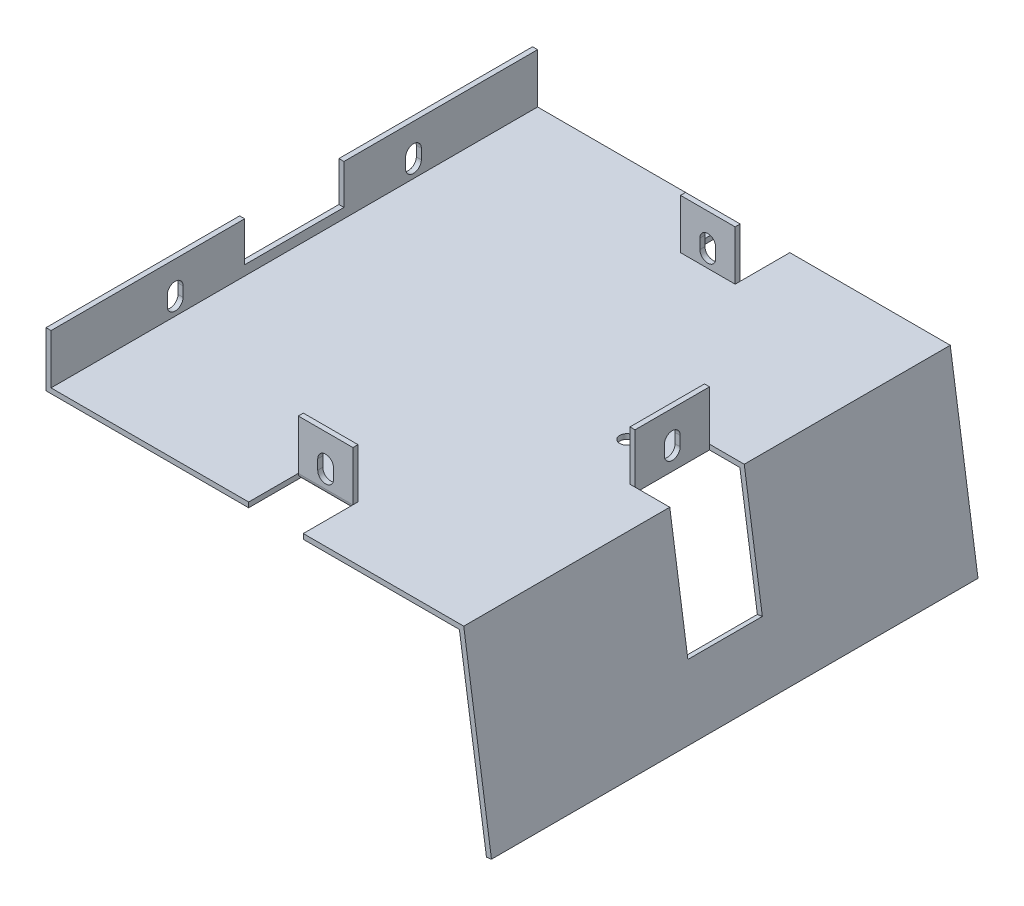
from build123d import *

# Parameters (mm, degrees)
BOSS_EXTRUDE1_DEPTH = 98
CUT_EXTRUDE1_REACH  = 40.016
SKETCH2_W           = 11
SKETCH2_H           = 10
SKETCH4_W           = 11
SKETCH4_H           = 10
BOSS_EXTRUDE2_DEPTH = 1.016
FILLET2_R           = 1
CUT_EXTRUDE2_REACH  = 40.016
SKETCH6_R           = 1.4224
FILLET4_R           = 1
CUT_EXTRUDE4_REACH  = 91.728
SKETCH8_W           = 20
SKETCH8_H           = 8.016
CUT_EXTRUDE5_REACH  = 90.79
SKETCH9_W           = 15
SKETCH9_H           = 22
CUT_EXTRUDE6_REACH  = 40.016
SKETCH11_W          = 15
SKETCH11_H          = 10
BOSS_EXTRUDE4_DEPTH = 1.016
CUT_EXTRUDE7_REACH  = 79.143


with BuildPart() as part:
    # Sketch1 → Boss-Extrude1 (new body)
    with BuildSketch(Plane.XY):
        Polygon((0, 0), (-5.457086284, 37), (-87.707086284, 37), (-88.723086284, 37), (-88.723086284, 48.016), (-87.707086284, 48.016), (-87.707086284, 38.016), (-4.579943874, 38.016), (1.005126579, 0.148244932), align=None)
    extrude(amount=BOSS_EXTRUDE1_DEPTH)

    # Sketch2 → Cut-Extrude1 (cut, up to next)
    with BuildSketch(Plane(origin=(0, 38.016, 0), x_dir=(1, 0, 0), z_dir=(0, 1, 0)), mode=Mode.PRIVATE) as cut_extrude1_sk1:
        with Locations((-42.399943874, -5)):
            Rectangle(SKETCH2_W, SKETCH2_H)
    cut_extrude1_tool1 = extrude(cut_extrude1_sk1.sketch, amount=-CUT_EXTRUDE1_REACH, mode=Mode.PRIVATE) & part.part
    add(cut_extrude1_tool1.solids().sort_by_distance((-42.399944, 38.016, 5))[0], mode=Mode.SUBTRACT)
    # Sketch2 → Cut-Extrude1 (cut, up to next)
    with BuildSketch(Plane(origin=(0, 38.016, 0), x_dir=(1, 0, 0), z_dir=(0, 1, 0)), mode=Mode.PRIVATE) as cut_extrude1_sk2:
        with Locations((-42.399943874, -93)):
            Rectangle(SKETCH2_W, SKETCH2_H)
    cut_extrude1_tool2 = extrude(cut_extrude1_sk2.sketch, amount=-CUT_EXTRUDE1_REACH, mode=Mode.PRIVATE) & part.part
    add(cut_extrude1_tool2.solids().sort_by_distance((-42.399944, 38.016, 93))[0], mode=Mode.SUBTRACT)

    # Sketch4 → Boss-Extrude2 (add)
    with BuildSketch(Plane(origin=(0, 0, 10), x_dir=(-1, 0, 0), z_dir=(0, 0, -1))):
        with Locations((42.399943874, 43.016)):
            Rectangle(SKETCH4_W, SKETCH4_H)
        with BuildLine():
            Line((43.989943874, 40.516), (43.989943874, 42.516))
            ThreePointArc((43.989943874, 42.516), (42.399943874, 44.106), (40.809943874, 42.516))
            Line((40.809943874, 42.516), (40.809943874, 40.516))
            ThreePointArc((40.809943874, 40.516), (42.399943874, 38.926), (43.989943874, 40.516))
        make_face(mode=Mode.SUBTRACT)
    boss_extrude2 = extrude(amount=-BOSS_EXTRUDE2_DEPTH)

    # Fillet2
    fillet2_edges = [part.edges().sort_by_distance(p)[0] for p in [
        (-42.399943874, 37, 10),
    ]]
    fillet(fillet2_edges, radius=FILLET2_R)

    # Sketch6 → Cut-Extrude2 (cut, up to next)
    with BuildSketch(Plane(origin=(0, 38.016, 0), x_dir=(1, 0, 0), z_dir=(0, 1, 0)), mode=Mode.PRIVATE) as cut_extrude2_sk1:
        with Locations((-20.739943874, -49)):
            Circle(SKETCH6_R)
    cut_extrude2_tool1 = extrude(cut_extrude2_sk1.sketch, amount=-CUT_EXTRUDE2_REACH, mode=Mode.PRIVATE) & part.part
    add(cut_extrude2_tool1.solids().sort_by_distance((-20.739944, 38.016, 49))[0], mode=Mode.SUBTRACT)

    # Mirror4: Boss-Extrude2 across plane
    add(boss_extrude2.mirror(Plane.XY.offset(49)))

    # Fillet4
    fillet4_edges = [part.edges().sort_by_distance(p)[0] for p in [
        (-42.399943874, 37, 88),
    ]]
    fillet(fillet4_edges, radius=FILLET4_R)

    # Sketch8 → Cut-Extrude4 (cut, up to next)
    with BuildSketch(Plane.ZY.offset(88.723086284), mode=Mode.PRIVATE) as cut_extrude4_sk1:
        with BuildLine():
            Line((23.41, 42.516), (23.41, 40.516))
            ThreePointArc((23.41, 40.516), (25, 38.926), (26.59, 40.516))
            Line((26.59, 40.516), (26.59, 42.516))
            ThreePointArc((26.59, 42.516), (25, 44.106), (23.41, 42.516))
        make_face()
    cut_extrude4_tool1 = extrude(cut_extrude4_sk1.sketch, amount=-CUT_EXTRUDE4_REACH, mode=Mode.PRIVATE) & part.part
    add(cut_extrude4_tool1.solids().sort_by_distance((-88.723086, 41.516, 25))[0], mode=Mode.SUBTRACT)
    # Sketch8 → Cut-Extrude4 (cut, up to next)
    with BuildSketch(Plane.ZY.offset(88.723086284), mode=Mode.PRIVATE) as cut_extrude4_sk2:
        with BuildLine():
            Line((71.41, 42.516), (71.41, 40.516))
            ThreePointArc((71.41, 40.516), (73, 38.926), (74.59, 40.516))
            Line((74.59, 40.516), (74.59, 42.516))
            ThreePointArc((74.59, 42.516), (73, 44.106), (71.41, 42.516))
        make_face()
    cut_extrude4_tool2 = extrude(cut_extrude4_sk2.sketch, amount=-CUT_EXTRUDE4_REACH, mode=Mode.PRIVATE) & part.part
    add(cut_extrude4_tool2.solids().sort_by_distance((-88.723086, 41.516, 73))[0], mode=Mode.SUBTRACT)
    # Sketch8 → Cut-Extrude4 (cut, up to next)
    with BuildSketch(Plane.ZY.offset(88.723086284), mode=Mode.PRIVATE) as cut_extrude4_sk3:
        with Locations((49, 44.008)):
            Rectangle(SKETCH8_W, SKETCH8_H)
    cut_extrude4_tool3 = extrude(cut_extrude4_sk3.sketch, amount=-CUT_EXTRUDE4_REACH, mode=Mode.PRIVATE) & part.part
    add(cut_extrude4_tool3.solids().sort_by_distance((-88.723086, 44.008, 49))[0], mode=Mode.SUBTRACT)

    # Sketch9 → Cut-Extrude5 (cut, up to next)
    with BuildSketch(Plane(origin=(1.005126579, 0.148244932, 0), x_dir=(0, 0, -1), z_dir=(0.989297814, 0.145910366, 0)), mode=Mode.PRIVATE) as cut_extrude5_sk1:
        with Locations((-49, 24.27740699)):
            Rectangle(SKETCH9_W, SKETCH9_H)
    cut_extrude5_tool1 = extrude(cut_extrude5_sk1.sketch, amount=-CUT_EXTRUDE5_REACH, mode=Mode.PRIVATE) & part.part
    add(cut_extrude5_tool1.solids().sort_by_distance((-2.537199, 24.165831, 49))[0], mode=Mode.SUBTRACT)

    # Sketch10 → Cut-Extrude6 (cut, up to next)
    with BuildSketch(Plane(origin=(0, 38.016, 0), x_dir=(1, 0, 0), z_dir=(0, 1, 0)), mode=Mode.PRIVATE) as cut_extrude6_sk1:
        Polygon((-4.579943874, -56.5), (-11.579943874, -56.5), (-11.579943874, -41.5), (-4.579943874, -41.5), (-1.579943874, -41.5), (-1.579943874, -56.5), align=None)
    cut_extrude6_tool1 = extrude(cut_extrude6_sk1.sketch, amount=-CUT_EXTRUDE6_REACH, mode=Mode.PRIVATE) & part.part
    add(cut_extrude6_tool1.solids().sort_by_distance((-6.579944, 38.016, 49))[0], mode=Mode.SUBTRACT)

    # Sketch11 → Boss-Extrude4 (add)
    with BuildSketch(Plane(origin=(-11.579943874, 0, 0), x_dir=(0, 0, -1), z_dir=(1, 0, 0))):
        with Locations((-49, 43.016)):
            Rectangle(SKETCH11_W, SKETCH11_H)
    extrude(amount=-BOSS_EXTRUDE4_DEPTH)

    # Sketch12 → Cut-Extrude7 (cut, up to next)
    with BuildSketch(Plane(origin=(-11.579943874, 0, 0), x_dir=(0, 0, -1), z_dir=(1, 0, 0)), mode=Mode.PRIVATE) as cut_extrude7_sk1:
        with BuildLine():
            Line((-50.59, 42.516), (-50.59, 40.516))
            ThreePointArc((-50.59, 40.516), (-49, 38.926), (-47.41, 40.516))
            Line((-47.41, 40.516), (-47.41, 42.516))
            ThreePointArc((-47.41, 42.516), (-49, 44.106), (-50.59, 42.516))
        make_face()
    cut_extrude7_tool1 = extrude(cut_extrude7_sk1.sketch, amount=-CUT_EXTRUDE7_REACH, mode=Mode.PRIVATE) & part.part
    add(cut_extrude7_tool1.solids().sort_by_distance((-11.579944, 41.516, 49))[0], mode=Mode.SUBTRACT)


solid = part.part
